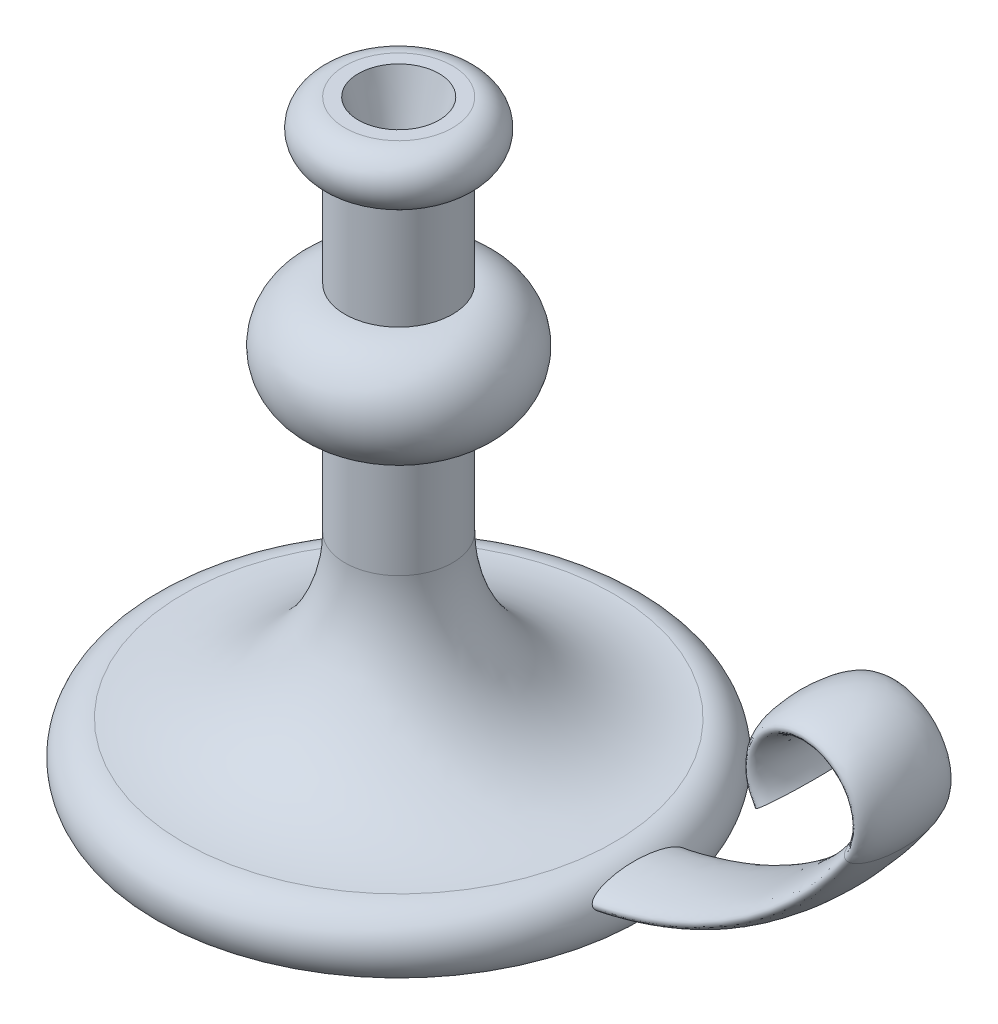
from build123d import *

# Parameters (mm, degrees)
SKETCH3_RX         = 17.5
SKETCH3_RY         = 5
SKETCH4_R          = 15
CUT_EXTRUDE1_DEPTH = 25
CUT_EXTRUDE1_TAPER = 15


with BuildPart() as part:
    # Sketch1 → Revolve1 (revolve)
    with BuildSketch(Plane.XY):
        with BuildLine():
            Line((0, 0), (0, 220))
            Line((0, 220), (20, 220))
            ThreePointArc((20, 220), (30, 210), (20, 200))
            Line((20, 200), (20, 160))
            ThreePointArc((20, 160), (40, 140), (20, 120))
            Line((20, 120), (20, 80))
            ThreePointArc((20, 80), (37.573593129, 37.573593129), (80, 20))
            ThreePointArc((80, 20), (91.180339887, 13.090169944), (90, 0))
            Line((90, 0), (0, 0))
        make_face()
    revolve(axis=Axis((0, 0, 0), (0, 1, 0)))

    # Sweep1: sweep along a path in Sketch2
    with BuildLine(Plane.XY) as sweep1_path:
        Line((0, 10), (60, 10))
        ThreePointArc((60, 10), (129.821200219, 27.240819526), (183.592070943, 75))
        ThreePointArc((183.592070943, 75), (167.113128151, 106.333333333), (150.634185358, 75))
    # Sketch3 → Sweep1 (sweep)
    with BuildSketch(Plane(origin=(0, 0, 0), x_dir=(0, 0, -1), z_dir=(1, 0, 0))):
        with Locations(Location((0, 10), (0, 0, 180))):
            Ellipse(SKETCH3_RX, SKETCH3_RY)
    sweep(path=sweep1_path.line)

    # Sketch4 → Cut-Extrude1 (cut)
    with BuildSketch(Plane(origin=(0, 220, 0), x_dir=(1, 0, 0), z_dir=(0, 1, 0))):
        Circle(SKETCH4_R)
    extrude(amount=-CUT_EXTRUDE1_DEPTH, taper=CUT_EXTRUDE1_TAPER, mode=Mode.SUBTRACT)


solid = part.part
